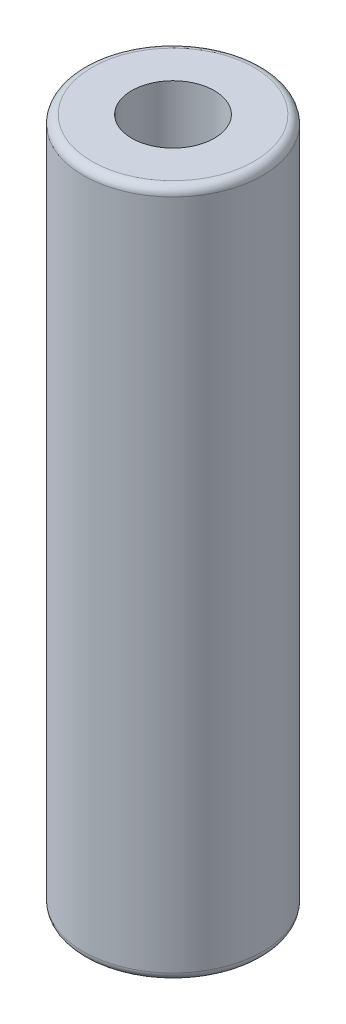
from build123d import *

# Parameters (mm, degrees)
ESBO_O1_R                = 3.25
RESSALTO_EXTRUS_O1_DEPTH = 25
ESBO_O2_R                = 1.5
CORTE_EXTRUS_O1_DEPTH    = 26
FILETE1_R                = 0.3


with BuildPart() as part:
    # Esboço1 → Ressalto-extrusão1 (new body)
    with BuildSketch(Plane(origin=(0, 0, 0), x_dir=(1, 0, 0), z_dir=(0, 1, 0))):
        Circle(ESBO_O1_R)
    extrude(amount=RESSALTO_EXTRUS_O1_DEPTH)

    # Esboço2 → Corte-extrusão1 (cut, through all)
    with BuildSketch(Plane(origin=(0, 25, 0), x_dir=(1, 0, 0), z_dir=(0, 1, 0))):
        Circle(ESBO_O2_R)
    extrude(amount=-CORTE_EXTRUS_O1_DEPTH, mode=Mode.SUBTRACT)

    # Filete1
    filete1_edges = [part.edges().sort_by_distance(p)[0] for p in [
        (-3.25, 0, 0),
        (-3.25, 25, 0),
    ]]
    fillet(filete1_edges, radius=FILETE1_R)


solid = part.part
